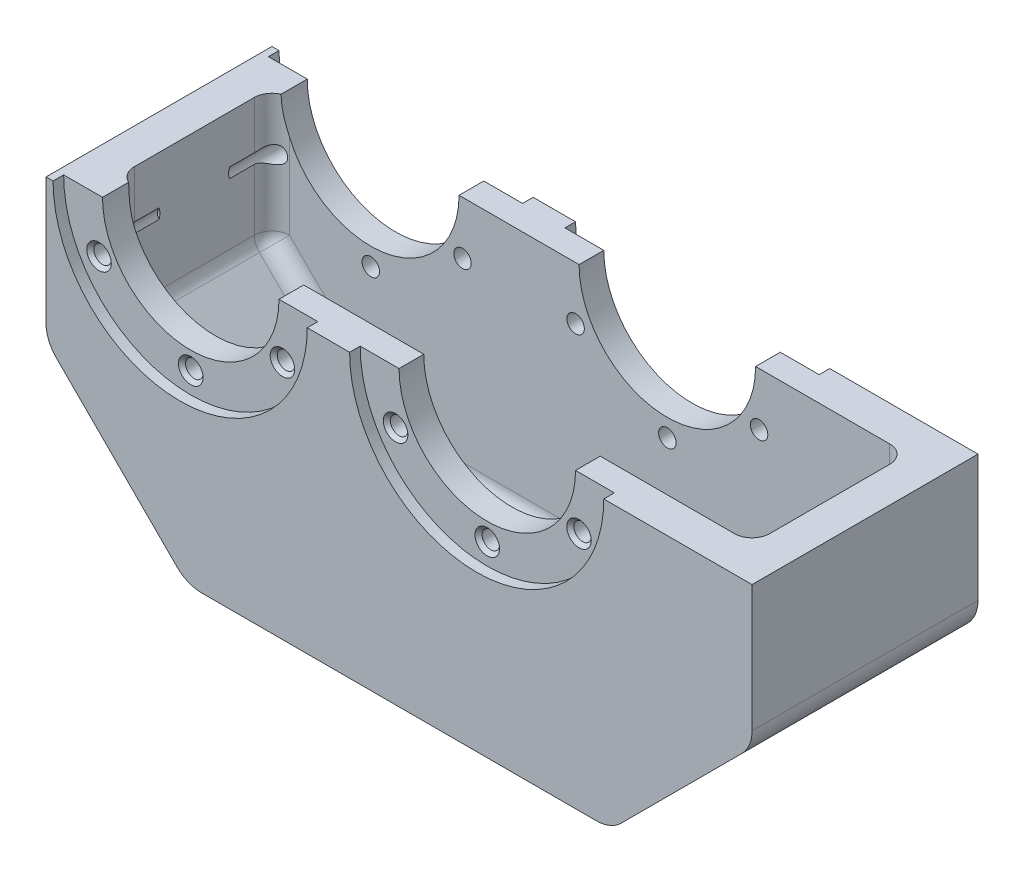
from build123d import *

# Parameters (mm, degrees)
EXTRUDE_1_DEPTH          = 32
SHELL_1_T                = -10
SKETCH_2_R               = 36
CUT_EXTRUDE_1_DEPTH      = 3
SKETCH_3_R               = 36
CUT_EXTRUDE_2_DEPTH      = 3
FILLET_1_R               = 5
FILLET_2_R               = 10
PATTERN_CIRCULAR_1_COUNT = 6
PATTERN_CIRCULAR_2_COUNT = 6


with BuildPart() as part:
    # Эскиз1 → Бобышка-Вытянуть1 (new body, symmetric)
    with BuildSketch(Plane.XY):
        with BuildLine():
            Line((-38, 0), (-25, 0))
            ThreePointArc((-25, 0), (0, -25), (25, 0))
            Line((25, 0), (59, 0))
            ThreePointArc((59, 0), (84, -25), (109, 0))
            Line((109, 0), (162, 0))
            Line((162, 0), (162, -40))
            Line((162, -40), (122, -80))
            Line((122, -80), (2, -80))
            Line((2, -80), (-38, -40))
            Line((-38, -40), (-38, 0))
        make_face()
    extrude(amount=EXTRUDE_1_DEPTH, both=True)

    # Оболочка1
    shell_1_openings = [part.faces().sort_by_distance(p)[0] for p in [
        (-31.5, 0, 0),
        (0, -12.5, 0),
        (42, 0, 0),
        (84, -12.5, 0),
        (135.5, 0, 0),
    ]]
    offset(amount=SHELL_1_T, openings=shell_1_openings, kind=Kind.INTERSECTION)

    # Эскиз2 → Вырез-Вытянуть1 (cut)
    with BuildSketch(Plane.XY.offset(32)):
        Circle(SKETCH_2_R)
        with Locations((84, 0)):
            Circle(SKETCH_2_R)
    extrude(amount=-CUT_EXTRUDE_1_DEPTH, mode=Mode.SUBTRACT)

    # Эскиз3 → Вырез-Вытянуть2 (cut)
    with BuildSketch(Plane(origin=(0, 0, -32), x_dir=(-1, 0, 0), z_dir=(0, 0, -1))):
        Circle(SKETCH_3_R)
        with Locations((-84, 0)):
            Circle(SKETCH_3_R)
    extrude(amount=-CUT_EXTRUDE_2_DEPTH, mode=Mode.SUBTRACT)

    # Скругление1
    fillet_1_edges = [part.edges().sort_by_distance(p)[0] for p in [
        (-28, -17.928932188, -22),
        (-10.928932188, -52.928932188, -22),
        (-28, -35.857864376, 0),
        (62, -70, -22),
        (6.142135624, -70, 0),
        (134.928932188, -52.928932188, -22),
        (117.857864376, -70, 0),
        (152, -17.928932188, -22),
        (152, -35.857864376, 0),
        (-28, -17.928932188, 22),
        (-10.928932188, -52.928932188, 22),
        (62, -70, 22),
        (134.928932188, -52.928932188, 22),
        (152, -17.928932188, 22),
    ]]
    fillet(fillet_1_edges, radius=FILLET_1_R)

    # Скругление2
    fillet_2_edges = [part.edges().sort_by_distance(p)[0] for p in [
        (162, -40, 0),
        (122, -80, 0),
        (2, -80, 0),
        (-38, -40, 0),
    ]]
    fillet(fillet_2_edges, radius=FILLET_2_R)

    # Эскиз6 → Отверстие обработанное метчиком M61 (revolve, cut)
    with BuildSketch(Plane(origin=(0, -30, 29), x_dir=(0, -1, 0), z_dir=(1, 0, 0))):
        Polygon((0, 0), (0, 20.487130032), (2.475, 19), (2.475, 1), (3.475, 0), align=None)
    hole_wizard_m61 = revolve(axis=Axis((0, -30, 35.35), (0, 0, -1)), mode=Mode.SUBTRACT)

    # Эскиз8 → Отверстие обработанное метчиком M62 (revolve, cut)
    with BuildSketch(Plane(origin=(0, -30, -29), x_dir=(0, 1, 0), z_dir=(1, 0, 0))):
        Polygon((0, 0), (0, 20.487130032), (2.475, 19), (2.475, 1), (3.475, 0), align=None)
    hole_wizard_m62 = revolve(axis=Axis((0, -30, -35.35), (0, 0, 1)), mode=Mode.SUBTRACT)

    # Круговой массив1: Отверстие обработанное метчиком M61, Отверстие обработанное метчиком M62 ×6 about axis, 3 skipped
    pattern_circular_1_axis = Axis((0, 0, 0), (0, 0, 1))
    add([hole_wizard_m61.rotate(pattern_circular_1_axis, i * 360 / PATTERN_CIRCULAR_1_COUNT) for i in range(1, PATTERN_CIRCULAR_1_COUNT) if i not in (2, 3, 4)], mode=Mode.SUBTRACT)
    add([hole_wizard_m62.rotate(pattern_circular_1_axis, i * 360 / PATTERN_CIRCULAR_1_COUNT) for i in range(1, PATTERN_CIRCULAR_1_COUNT) if i not in (2, 3, 4)], mode=Mode.SUBTRACT)

    # Эскиз10 → Отверстие обработанное метчиком M63 (revolve, cut)
    with BuildSketch(Plane(origin=(84, -30, 29), x_dir=(0, -1, 0), z_dir=(1, 0, 0))):
        Polygon((0, 0), (0, 20.487130032), (2.475, 19), (2.475, 1), (3.475, 0), align=None)
    hole_wizard_m63 = revolve(axis=Axis((84, -30, 35.35), (0, 0, -1)), mode=Mode.SUBTRACT)

    # Эскиз12 → Отверстие обработанное метчиком M64 (revolve, cut)
    with BuildSketch(Plane(origin=(84, -30, -29), x_dir=(0, 1, 0), z_dir=(1, 0, 0))):
        Polygon((0, 0), (0, 20.487130032), (2.475, 19), (2.475, 1), (3.475, 0), align=None)
    hole_wizard_m64 = revolve(axis=Axis((84, -30, -35.35), (0, 0, 1)), mode=Mode.SUBTRACT)

    # Круговой массив2: Отверстие обработанное метчиком M63, Отверстие обработанное метчиком M64 ×6 about axis, 3 skipped
    pattern_circular_2_axis = Axis((84, 0, 0), (0, 0, -1))
    add([hole_wizard_m63.rotate(pattern_circular_2_axis, i * 360 / PATTERN_CIRCULAR_2_COUNT) for i in range(1, PATTERN_CIRCULAR_2_COUNT) if i not in (2, 3, 4)], mode=Mode.SUBTRACT)
    add([hole_wizard_m64.rotate(pattern_circular_2_axis, i * 360 / PATTERN_CIRCULAR_2_COUNT) for i in range(1, PATTERN_CIRCULAR_2_COUNT) if i not in (2, 3, 4)], mode=Mode.SUBTRACT)


solid = part.part
